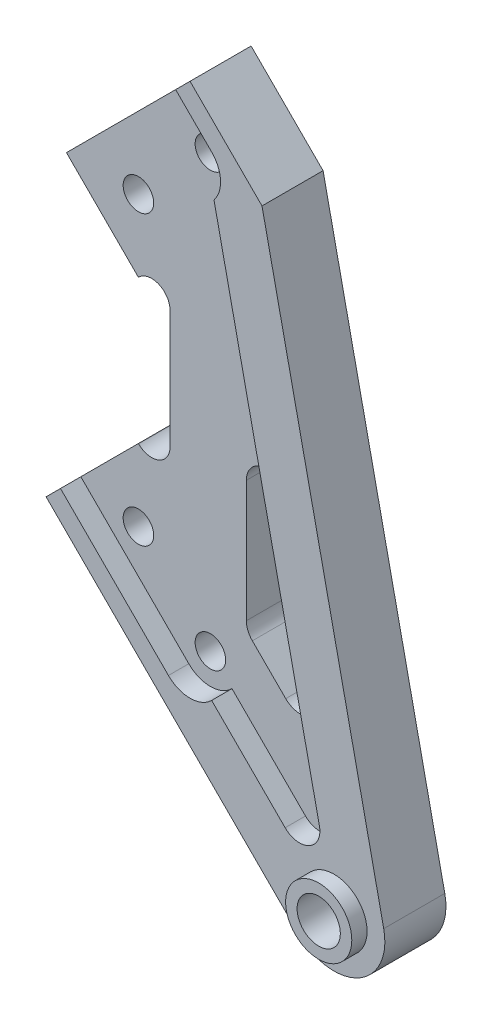
from build123d import *

# Parameters (mm, degrees)
SKETCH1_R           = 3
SKETCH1_R_2         = 4.25
BOSS_EXTRUDE1_DEPTH = 8
SKETCH2_R           = 4.25
BOSS_EXTRUDE2_DEPTH = 4
SKETCH3_R           = 6.5
SKETCH3_R_2         = 4.25
BOSS_EXTRUDE3_DEPTH = 3


with BuildPart() as part:
    # Sketch1 → Boss-Extrude1 (new body)
    with BuildSketch(Plane.XY):
        with BuildLine():
            Line((-15.213203436, 14.142135624), (-15.171572875, 14.183766184))
            ThreePointArc((-15.171572875, 14.183766184), (-11.231737479, 14.96744817), (-9, 11.627416998))
            Line((-9, 11.627416998), (-9, -11.627416998))
            ThreePointArc((-9, -11.627416998), (-11.231737479, -14.96744817), (-15.171572875, -14.183766184))
            Line((-15.171572875, -14.183766184), (-15.213203436, -14.142135624))
            Line((-15.213203436, -14.142135624), (-29.355339059, -28.284271247))
            Line((-29.355339059, -28.284271247), (20.142135624, -77.781745931))
            ThreePointArc((20.142135624, -77.781745931), (31.996800536, -79.492317987), (36.988958333, -68.60482528))
            Line((36.988958333, -68.60482528), (13.071067812, 42.426406871))
            Line((13.071067812, 42.426406871), (-1.071067812, 56.568542495))
            Line((-1.071067812, 56.568542495), (-29.355339059, 28.284271247))
            Line((-29.355339059, 28.284271247), (-15.213203436, 14.142135624))
        make_face()
        with Locations((-1.071067812, 42.426406871)):
            Circle(SKETCH1_R, mode=Mode.SUBTRACT)
        with Locations((-15.213203436, 28.284271247)):
            Circle(SKETCH1_R, mode=Mode.SUBTRACT)
        with Locations((-15.213203436, -28.284271247)):
            Circle(SKETCH1_R, mode=Mode.SUBTRACT)
        with Locations((-1.071067812, -42.426406871)):
            Circle(SKETCH1_R, mode=Mode.SUBTRACT)
        with Locations((27.213203436, -70.710678119)):
            Circle(SKETCH1_R_2, mode=Mode.SUBTRACT)
        with BuildLine():
            Line((6, -9.798512067), (6, -33.69848481))
            ThreePointArc((6, -33.69848481), (6.30448187, -35.229218539), (7.171572875, -36.526911935))
            Line((7.171572875, -36.526911935), (13.733563505, -43.088902565))
            ThreePointArc((13.733563505, -43.088902565), (18.47542947, -43.773131388), (20.472292589, -39.418134305))
            Line((20.472292589, -39.418134305), (13.910301959, -8.956170931))
            ThreePointArc((13.910301959, -8.956170931), (9.576448254, -5.820999789), (6, -9.798512067))
        make_face(mode=Mode.SUBTRACT)
    extrude(amount=BOSS_EXTRUDE1_DEPTH)

    # Sketch2 → Boss-Extrude2 (add)
    with BuildSketch(Plane.XY.offset(8)):
        with BuildLine():
            Line((24.355165698, -57.443143037), (3.641635622, 38.712860541))
            ThreePointArc((3.641635622, 38.712860541), (4.918487685, 42.780278254), (3.171572875, 46.669047558))
            Line((3.171572875, 46.669047558), (-3.899494937, 53.74011537))
            Line((-3.899494937, 53.74011537), (-1.071067812, 56.568542495))
            Line((-1.071067812, 56.568542495), (13.071067812, 42.426406871))
            Line((13.071067812, 42.426406871), (36.988958333, -68.60482528))
            ThreePointArc((36.988958333, -68.60482528), (31.996800536, -79.492317987), (20.142135624, -77.781745931))
            Line((20.142135624, -77.781745931), (-29.355339059, -28.284271247))
            Line((-29.355339059, -28.284271247), (-26.526911935, -25.455844123))
            Line((-26.526911935, -25.455844123), (-5.313708499, -46.669047558))
            ThreePointArc((-5.313708499, -46.669047558), (-1.071067812, -48.426406871), (3.171572875, -46.669047558))
            Line((3.171572875, -46.669047558), (17.616436614, -61.113911297))
            ThreePointArc((17.616436614, -61.113911297), (22.358302578, -61.79814012), (24.355165698, -57.443143037))
        make_face()
        with Locations((27.213203436, -70.710678119)):
            Circle(SKETCH2_R, mode=Mode.SUBTRACT)
    extrude(amount=BOSS_EXTRUDE2_DEPTH)

    # Sketch3 → Boss-Extrude3 (add)
    with BuildSketch(Plane.XY.offset(12)):
        with Locations((27.213203436, -70.710678119)):
            Circle(SKETCH3_R)
        with Locations((27.213203436, -70.710678119)):
            Circle(SKETCH3_R_2, mode=Mode.SUBTRACT)
    extrude(amount=BOSS_EXTRUDE3_DEPTH)


solid = part.part
